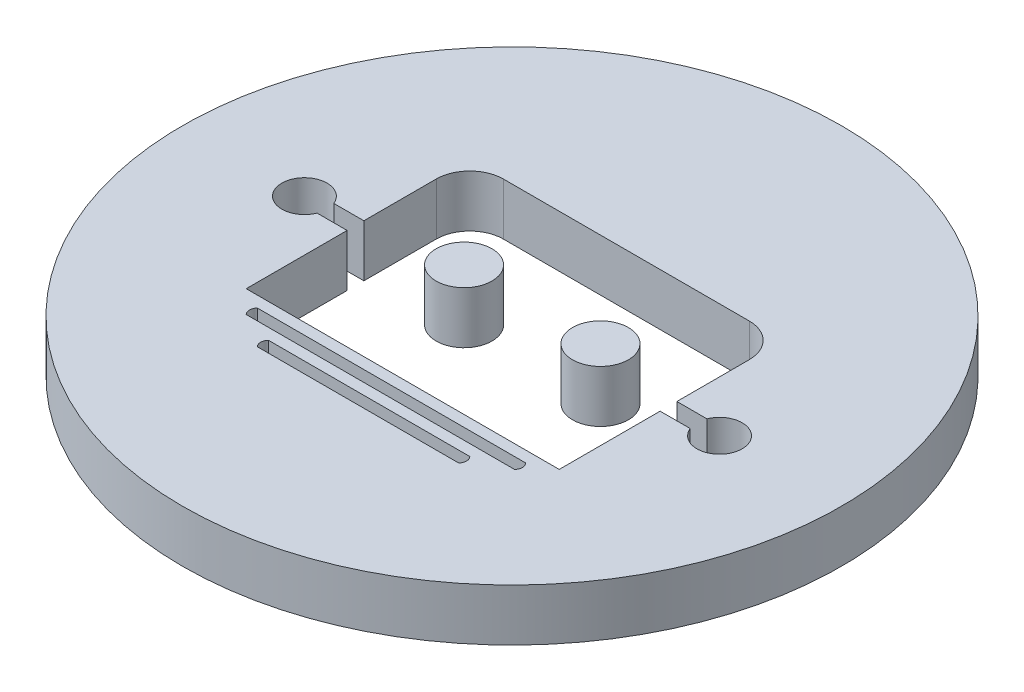
from build123d import *

# Parameters (mm, degrees)
SKETCH3_R           = 19
BOSS_EXTRUDE1_DEPTH = 3
SKETCH6_R           = 1.611255347
CUT_EXTRUDE1_DEPTH  = 4


with BuildPart() as part:
    # Sketch3 → Boss-Extrude1 (new body)
    with BuildSketch(Plane(origin=(0, 0, 0), x_dir=(1, 0, 0), z_dir=(0, 1, 0))):
        with Locations((-35.656522361, 86.864706092)):
            Circle(SKETCH3_R)
    extrude(amount=BOSS_EXTRUDE1_DEPTH)

    # Sketch6 → Cut-Extrude1 (cut, through all)
    with BuildSketch(Plane(origin=(0, 3, 0), x_dir=(1, 0, 0), z_dir=(0, 1, 0))):
        with BuildLine():
            Line((-44.679552304, 80.564265068), (-44.679552304, 86.381329488))
            Line((-44.679552304, 86.381329488), (-46.412185761, 86.381329488))
            ThreePointArc((-46.412185761, 86.381329488), (-48.925636161, 86.864706092), (-46.412185761, 87.348082696))
            Line((-46.412185761, 87.348082696), (-44.679552304, 87.348082696))
            Line((-44.679552304, 87.348082696), (-44.679552304, 91.520801428))
            ThreePointArc((-44.679552304, 91.520801428), (-44.113241386, 92.887996927), (-42.746045888, 93.454307845))
            Line((-42.746045888, 93.454307845), (-28.566998833, 93.454307845))
            ThreePointArc((-28.566998833, 93.454307845), (-27.199803335, 92.887996927), (-26.633492417, 91.520801428))
            Line((-26.633492417, 91.520801428), (-26.633492417, 87.348082696))
            Line((-26.633492417, 87.348082696), (-24.900858961, 87.348082696))
            ThreePointArc((-24.900858961, 87.348082696), (-22.38740856, 86.864706092), (-24.900858961, 86.381329488))
            Line((-24.900858961, 86.381329488), (-26.633492417, 86.381329488))
            Line((-26.633492417, 86.381329488), (-26.633492417, 80.564265068))
            Line((-26.633492417, 80.564265068), (-44.679552304, 80.564265068))
        make_face()
        with Locations((-39.588392261, 88.032660088)):
            Circle(SKETCH6_R, mode=Mode.SUBTRACT)
        with Locations((-31.72465246, 88.032660088)):
            Circle(SKETCH6_R, mode=Mode.SUBTRACT)
        with BuildLine():
            Line((-43.390548027, 79.919762929), (-27.922496694, 79.919762929))
            ThreePointArc((-27.922496694, 79.919762929), (-27.789015931, 79.597511859), (-27.922496694, 79.27526079))
            Line((-27.922496694, 79.27526079), (-43.390548027, 79.27526079))
            ThreePointArc((-43.390548027, 79.27526079), (-43.52402879, 79.597511859), (-43.390548027, 79.919762929))
        make_face()
        with BuildLine():
            Line((-41.45704161, 78.630758651), (-29.856003111, 78.630758651))
            ThreePointArc((-29.856003111, 78.630758651), (-29.722522348, 78.308507582), (-29.856003111, 77.986256512))
            Line((-29.856003111, 77.986256512), (-41.45704161, 77.986256512))
            ThreePointArc((-41.45704161, 77.986256512), (-41.590522374, 78.308507582), (-41.45704161, 78.630758651))
        make_face()
    extrude(amount=-CUT_EXTRUDE1_DEPTH, mode=Mode.SUBTRACT)


solid = part.part
